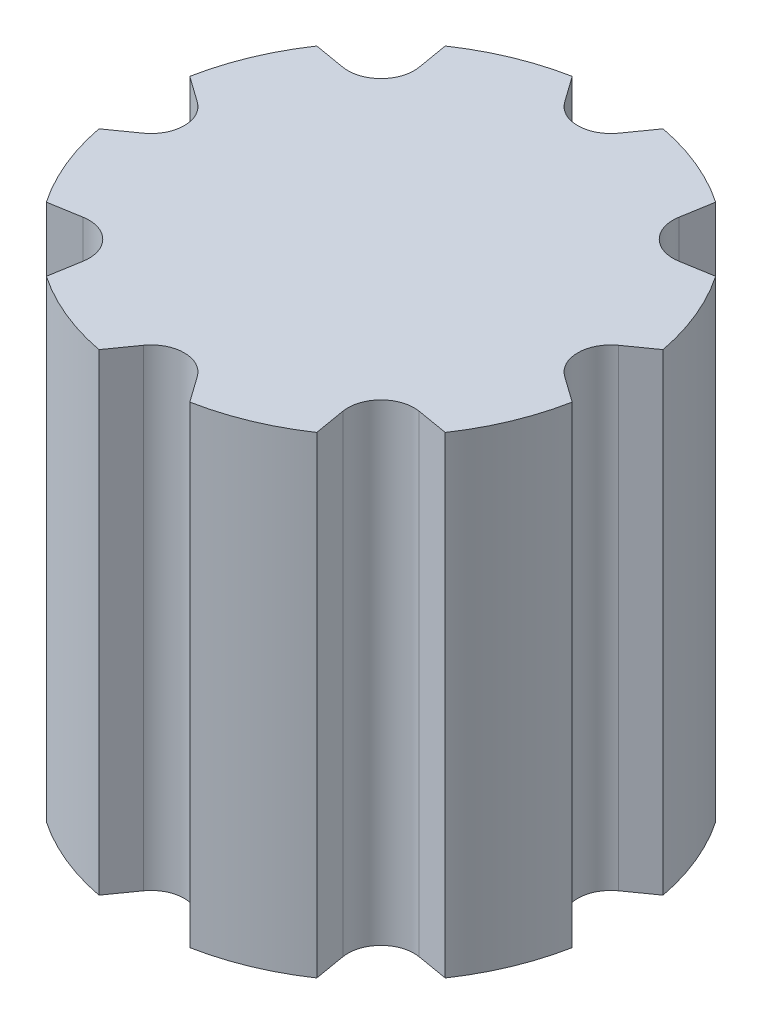
from build123d import *

# Parameters (mm, degrees)
BOSS_EXTRUDE1_DEPTH = 10
SKETCH2_R           = 1.5
CUT_EXTRUDE1_DEPTH  = 5


with BuildPart() as part:
    # Sketch1 → Boss-Extrude1 (new body)
    with BuildSketch(Plane(origin=(0, 0, 0), x_dir=(1, 0, 0), z_dir=(0, 1, 0))):
        with BuildLine():
            Line((-0.570751275, 4.458354836), (-0.96142982, 5.008557946))
            ThreePointArc((-0.96142982, 5.008557946), (-1.951685505, 4.711785616), (-2.861751742, 4.221418833))
            Line((-2.861751742, 4.221418833), (-2.748950841, 3.556115034))
            ThreePointArc((-2.748950841, 3.556115034), (-2.944126667, 2.944126667), (-3.556115034, 2.748950841))
            Line((-3.556115034, 2.748950841), (-4.221418833, 2.861751742))
            ThreePointArc((-4.221418833, 2.861751742), (-4.711785616, 1.951685505), (-5.008557946, 0.96142982))
            Line((-5.008557946, 0.96142982), (-4.458354836, 0.570751275))
            ThreePointArc((-4.458354836, 0.570751275), (-4.163623861, 0), (-4.458354836, -0.570751275))
            Line((-4.458354836, -0.570751275), (-5.008557946, -0.96142982))
            ThreePointArc((-5.008557946, -0.96142982), (-4.711785616, -1.951685505), (-4.221418833, -2.861751742))
            Line((-4.221418833, -2.861751742), (-3.556115034, -2.748950841))
            ThreePointArc((-3.556115034, -2.748950841), (-2.944126667, -2.944126667), (-2.748950841, -3.556115034))
            Line((-2.748950841, -3.556115034), (-2.861751742, -4.221418833))
            ThreePointArc((-2.861751742, -4.221418833), (-1.951685505, -4.711785616), (-0.96142982, -5.008557946))
            Line((-0.96142982, -5.008557946), (-0.570751275, -4.458354836))
            ThreePointArc((-0.570751275, -4.458354836), (0, -4.163623861), (0.570751275, -4.458354836))
            Line((0.570751275, -4.458354836), (0.96142982, -5.008557946))
            ThreePointArc((0.96142982, -5.008557946), (1.951685505, -4.711785616), (2.861751742, -4.221418833))
            Line((2.861751742, -4.221418833), (2.748950841, -3.556115034))
            ThreePointArc((2.748950841, -3.556115034), (2.944126667, -2.944126667), (3.556115034, -2.748950841))
            Line((3.556115034, -2.748950841), (4.221418833, -2.861751742))
            ThreePointArc((4.221418833, -2.861751742), (4.711785616, -1.951685505), (5.008557946, -0.96142982))
            Line((5.008557946, -0.96142982), (4.458354836, -0.570751275))
            ThreePointArc((4.458354836, -0.570751275), (4.163623861, 0), (4.458354836, 0.570751275))
            Line((4.458354836, 0.570751275), (5.008557946, 0.96142982))
            ThreePointArc((5.008557946, 0.96142982), (4.711785616, 1.951685505), (4.221418833, 2.861751742))
            Line((4.221418833, 2.861751742), (3.556115034, 2.748950841))
            ThreePointArc((3.556115034, 2.748950841), (2.944126667, 2.944126667), (2.748950841, 3.556115034))
            Line((2.748950841, 3.556115034), (2.861751742, 4.221418833))
            ThreePointArc((2.861751742, 4.221418833), (1.951685505, 4.711785616), (0.96142982, 5.008557946))
            Line((0.96142982, 5.008557946), (0.570751275, 4.458354836))
            ThreePointArc((0.570751275, 4.458354836), (0, 4.163623861), (-0.570751275, 4.458354836))
        make_face()
    extrude(amount=BOSS_EXTRUDE1_DEPTH)

    # Sketch2 → Cut-Extrude1 (cut)
    with BuildSketch(Plane.XZ):
        Circle(SKETCH2_R)
    extrude(amount=-CUT_EXTRUDE1_DEPTH, mode=Mode.SUBTRACT)


solid = part.part
